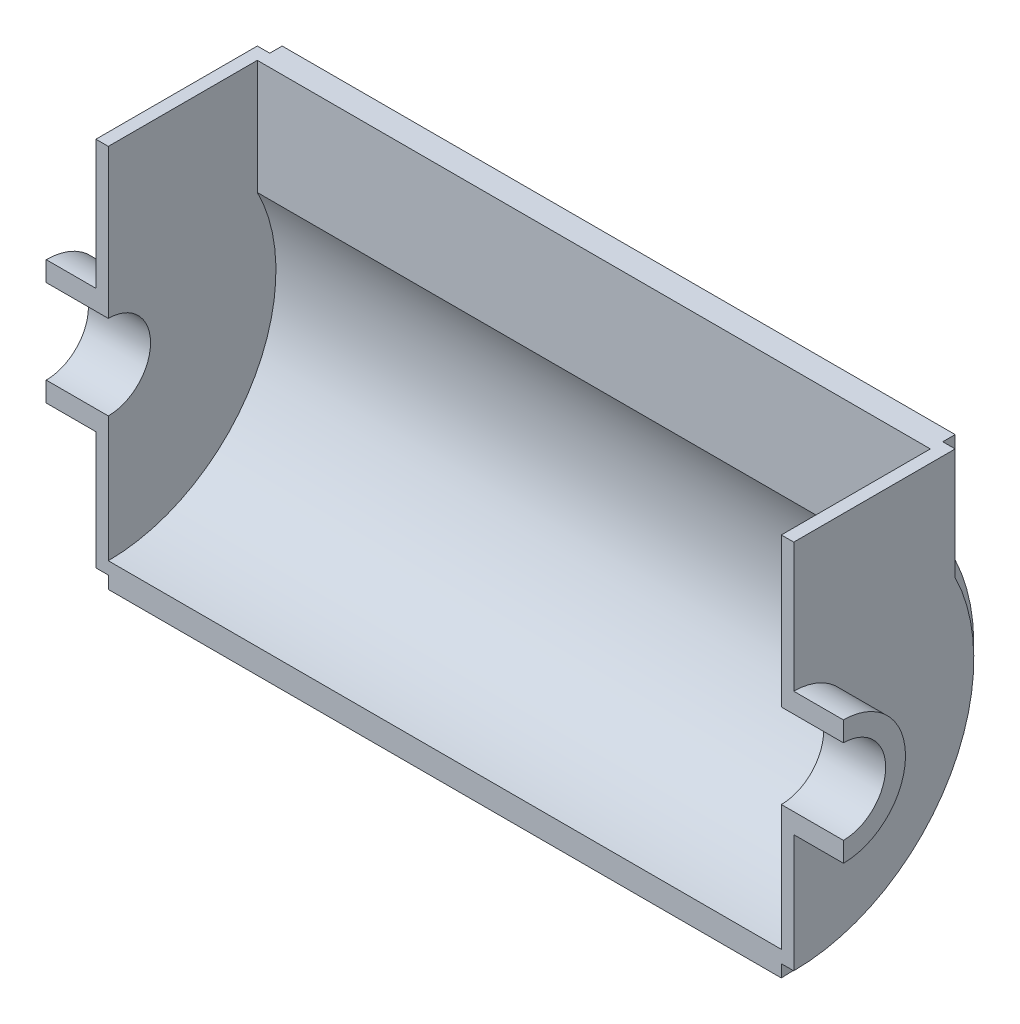
from build123d import *

# Parameters (mm, degrees)
Y_KSEKLIK_EKSTR_ZYON1_DEPTH = 20
Y_KSEKLIK_EKSTR_ZYON2_DEPTH = 5
EKSTR_ZYON_NCE4_DEPTH       = 271


with BuildPart() as part:
    # Çizim1 → Yükseklik-Ekstrüzyon1 (new body)
    with BuildSketch(Plane(origin=(0, 0, 0), x_dir=(0, 0, -1), z_dir=(1, 0, 0))):
        with BuildLine():
            Line((0, 25), (0, 17))
            ThreePointArc((0, 17), (17, 0), (0, -17))
            Line((0, -17), (0, -25))
            ThreePointArc((0, -25), (25, 0), (0, 25))
        make_face()
    extrude(amount=Y_KSEKLIK_EKSTR_ZYON1_DEPTH)

    # Çizim2 → Yükseklik-Ekstrüzyon2 (add)
    with BuildSketch(Plane(origin=(20, 0, 0), x_dir=(0, 0, -1), z_dir=(1, 0, 0))):
        with BuildLine():
            Line((0, 17), (0, 77))
            Line((0, 77), (65, 77))
            Line((65, 77), (65, 32.113081447))
            ThreePointArc((65, 32.113081447), (61.581037686, -38.262590053), (0, -72.5))
            Line((0, -72.5), (0, -17))
            ThreePointArc((0, -17), (17, 0), (0, 17))
        make_face()
    extrude(amount=Y_KSEKLIK_EKSTR_ZYON2_DEPTH)


with BuildPart() as body_2:
    # Aynalama4: mirrored copy
    add(part.part.mirror(Plane(origin=(160.5, 0, 0), x_dir=(0, 0, 1), z_dir=(1, 0, 0))))


with BuildPart() as part_1:
    add(part.part)

    add(body_2.part)  # Ekstrüzyon-İnce4 merges body 2
    # Çizim9 → Ekstrüzyon-İnce4 (add)
    with BuildSketch(Plane(origin=(25, 0, 0), x_dir=(0, 0, -1), z_dir=(1, 0, 0))):
        with BuildLine():
            ThreePointArc((0, -67.5), (57.634938288, -35.134938288), (60, 30.923292192))
            Line((60, 30.923292192), (60, 77))
            Line((60, 77), (70, 77))
            Line((70, 77), (70, 33.260336739))
            ThreePointArc((70, 33.260336739), (65.513075402, -41.4039485), (0, -77.5))
            Line((0, -77.5), (0, -67.5))
        make_face()
    extrude(amount=EKSTR_ZYON_NCE4_DEPTH)


solid = part_1.part
